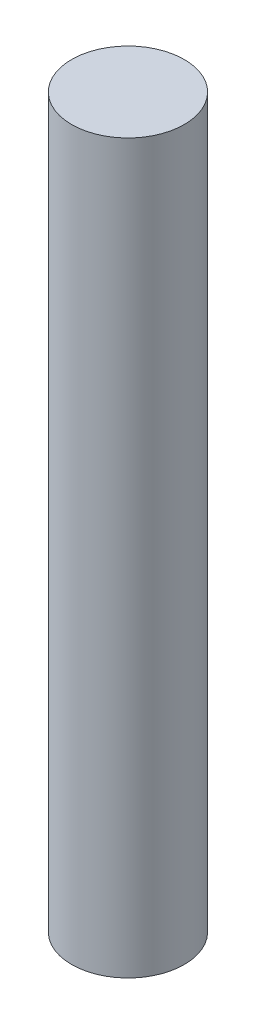
from build123d import *

# Parameters (mm, degrees)
SKETCH1_R           = 3.95
BOSS_EXTRUDE1_DEPTH = 51


with BuildPart() as part:
    # Sketch1 → Boss-Extrude1 (new body)
    with BuildSketch(Plane(origin=(0, 0, 0), x_dir=(1, 0, 0), z_dir=(0, 1, 0))):
        with Locations((-17.262341094, 6.389494373)):
            Circle(SKETCH1_R)
    extrude(amount=BOSS_EXTRUDE1_DEPTH)


solid = part.part
